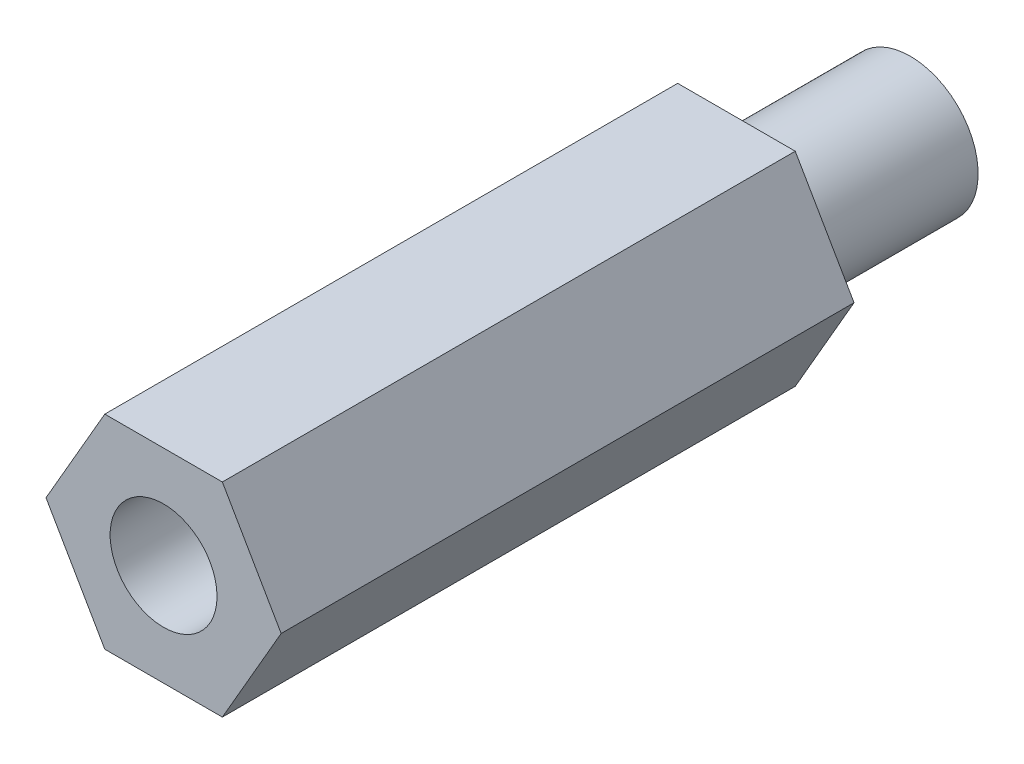
from build123d import *

# Parameters (mm, degrees)
BOSS_EXTRUDE1_DEPTH = 34.925
SKETCH2_R           = 2.5
CUT_EXTRUDE1_DEPTH  = 9.525
SKETCH4_OUTSIDE_W   = 20.564
SKETCH4_OUTSIDE_H   = 19.091
SKETCH4_OUTSIDE_R   = 3.175
CUT_EXTRUDE2_DEPTH  = 8.128


with BuildPart() as part:
    # Sketch1 → Boss-Extrude1 (new body)
    with BuildSketch(Plane.XY):
        Polygon((2.749630657, -4.7625), (5.499261314, 0), (2.749630657, 4.7625), (-2.749630657, 4.7625), (-5.499261314, 0), (-2.749630657, -4.7625), align=None)
    extrude(amount=BOSS_EXTRUDE1_DEPTH)

    # Sketch2 → Cut-Extrude1 (cut)
    with BuildSketch(Plane.XY.offset(34.925)):
        Circle(SKETCH2_R)
    extrude(amount=-CUT_EXTRUDE1_DEPTH, mode=Mode.SUBTRACT)

    # Sketch4 outside → Cut-Extrude2 (cut)
    with BuildSketch(Plane(origin=(0, 0, 0), x_dir=(-1, 0, 0), z_dir=(0, 0, -1))):
        with Locations((0, -0.0005)):
            Rectangle(SKETCH4_OUTSIDE_W, SKETCH4_OUTSIDE_H)
        Circle(SKETCH4_OUTSIDE_R, mode=Mode.SUBTRACT)
    extrude(amount=-CUT_EXTRUDE2_DEPTH, mode=Mode.SUBTRACT)


solid = part.part
